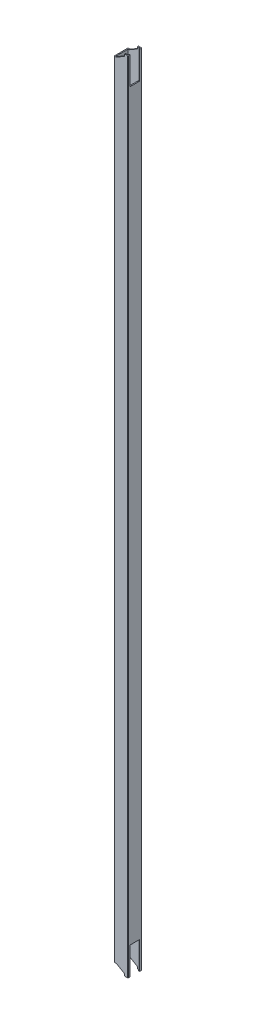
from build123d import *

# Parameters (mm, degrees)
SKETCH1_W           = 17
SKETCH1_H           = 17
BOSS_EXTRUDE1_DEPTH = 1156.4
CUT_EXTRUDE4_START  = -20
SKETCH5_W           = 14
SKETCH5_H           = 40
CUT_EXTRUDE4_DEPTH  = 10
CUT_EXTRUDE5_DEPTH  = 1157.745849355


with BuildPart() as part:
    # Sketch1 → Boss-Extrude1 (new body)
    with BuildSketch(Plane(origin=(0, 0, 0), x_dir=(1, 0, 0), z_dir=(0, 1, 0))):
        with BuildLine():
            Line((0.5, 0), (19.5, 0))
            ThreePointArc((19.5, 0), (19.853553391, 0.146446609), (20, 0.5))
            Line((20, 0.5), (20, 19.5))
            ThreePointArc((20, 19.5), (19.853553391, 19.853553391), (19.5, 20))
            Line((19.5, 20), (0.5, 20))
            ThreePointArc((0.5, 20), (0.146446609, 19.853553391), (0, 19.5))
            Line((0, 19.5), (0, 0.5))
            ThreePointArc((0, 0.5), (0.146446609, 0.146446609), (0.5, 0))
        make_face()
        with Locations((10, 10)):
            Rectangle(SKETCH1_W, SKETCH1_H, mode=Mode.SUBTRACT)
    extrude(amount=BOSS_EXTRUDE1_DEPTH)

    # Sketch5 → Cut-Extrude4 (cut)
    with BuildSketch(Plane.ZY.offset(CUT_EXTRUDE4_START)):
        with Locations((-10, 1136.4)):
            Rectangle(SKETCH5_W, SKETCH5_H)
    cut_extrude4 = extrude(amount=CUT_EXTRUDE4_DEPTH, mode=Mode.SUBTRACT)

    # Sketch6 → Cut-Extrude5 (cut, through all)
    with BuildSketch(Plane(origin=(0, 0, -20), x_dir=(-1, 0, 0), z_dir=(0, 0, -1))):
        Polygon((-15, 1156.4), (-15, 1153.4), (-3, 1146.4), (0, 1146.4), (0, 1156.4), align=None)
    cut_extrude5 = extrude(amount=-CUT_EXTRUDE5_DEPTH, mode=Mode.SUBTRACT)

    # Mirror1: Cut-Extrude4, Cut-Extrude5 across plane
    add(cut_extrude4.mirror(Plane.ZX.offset(578.2)), mode=Mode.SUBTRACT)
    add(cut_extrude5.mirror(Plane.ZX.offset(578.2)), mode=Mode.SUBTRACT)


solid = part.part
